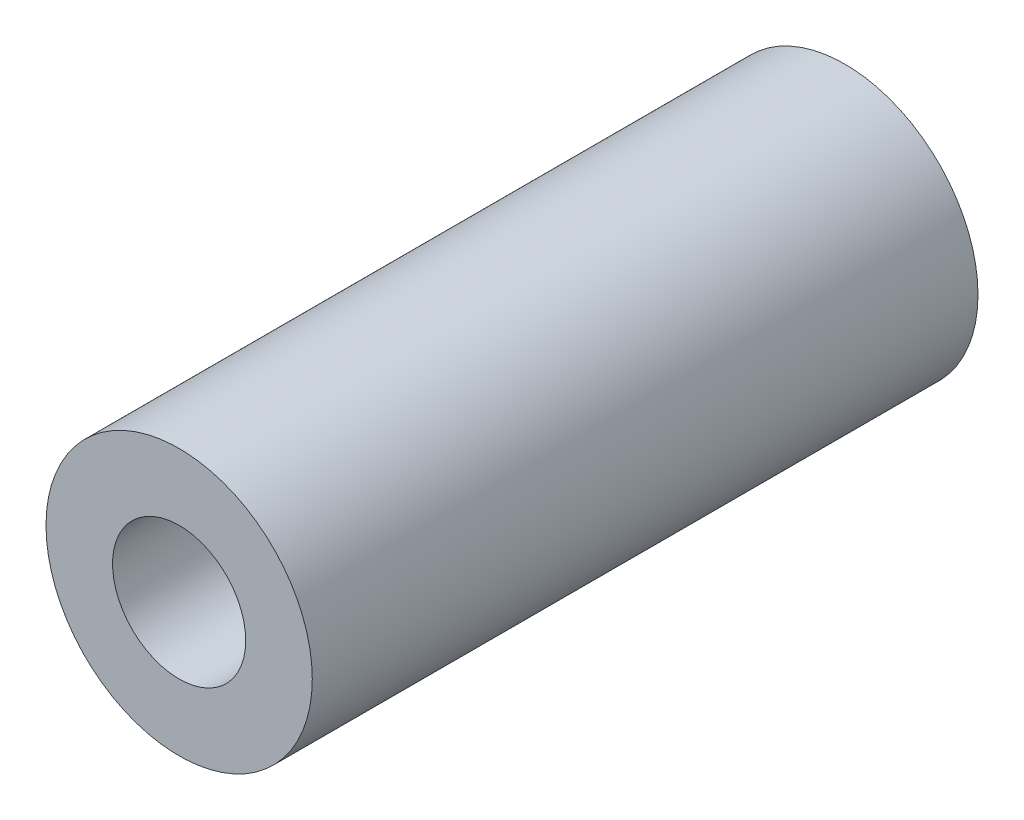
from build123d import *

# Parameters (mm, degrees)
ESQUISSE1_R   = 3
ESQUISSE1_R_2 = 1.5
MAIN_DEPTH    = 15


with BuildPart() as part:
    # Esquisse1 → Main (new body)
    with BuildSketch(Plane.XY):
        Circle(ESQUISSE1_R)
        Circle(ESQUISSE1_R_2, mode=Mode.SUBTRACT)
    extrude(amount=MAIN_DEPTH)


solid = part.part
